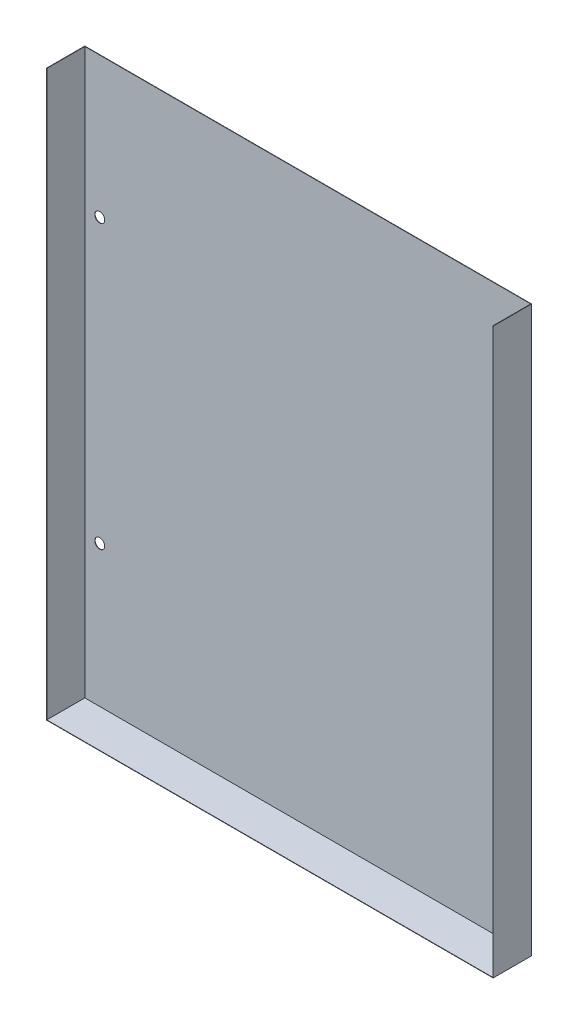
from build123d import *

# Parameters (mm, degrees)
SKETCH1_W            = 89.72
SKETCH1_H            = 227
SKETCH1_R            = 2
HEAT_EXCHANGER_DEPTH = 0.1524
CONVECTION_FIN_DEPTH = 15.45166


with BuildPart() as part:
    # Sketch1 → Heat Exchanger (new body)
    with BuildSketch(Plane.XY):
        with Locations((-44.86, 0)):
            Rectangle(SKETCH1_W, SKETCH1_H)
        with Locations((-83.72, -56.6738)):
            Circle(SKETCH1_R, mode=Mode.SUBTRACT)
        with Locations((-83.72, 56.9786)):
            Circle(SKETCH1_R, mode=Mode.SUBTRACT)
    heat_exchanger = extrude(amount=HEAT_EXCHANGER_DEPTH)

    # Sketch3 → Convection Fin (add)
    with BuildSketch(Plane.XY):
        Polygon((0, -113.6524), (0, -113.5), (-89.72, -113.5), (-89.72, 113.5), (-89.8724, 113.5), (-89.8724, -113.6524), align=None)
    convection_fin = extrude(amount=CONVECTION_FIN_DEPTH)

    # Mirror1: Heat Exchanger, Convection Fin across plane
    add(heat_exchanger.mirror(Plane(origin=(0, 0, 0), x_dir=(0, 0, 1), z_dir=(1, 0, 0))))
    add(convection_fin.mirror(Plane(origin=(0, 0, 0), x_dir=(0, 0, 1), z_dir=(1, 0, 0))))


solid = part.part
